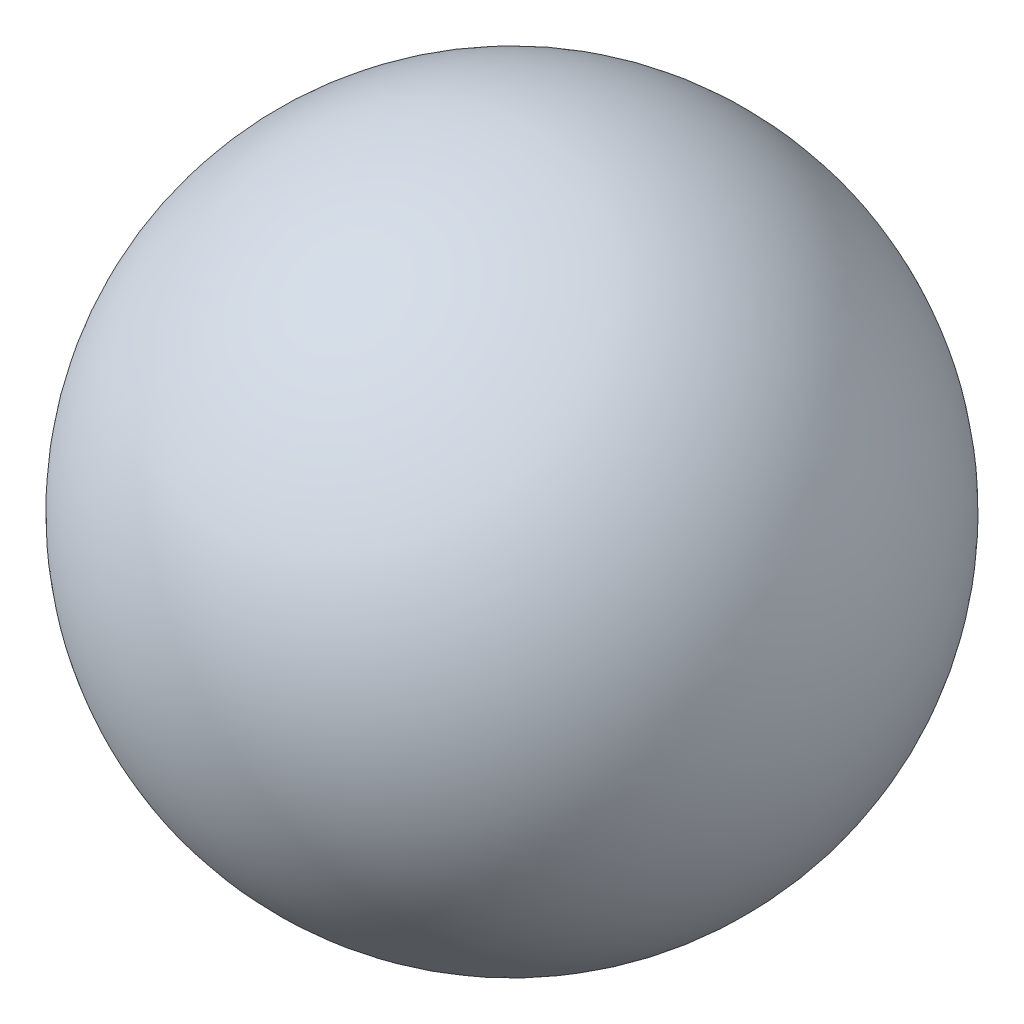
from build123d import *


with BuildPart() as part:
    # 草图1 one side → 旋转2 (revolve)
    with BuildSketch(Plane(origin=(0, 0, 0), x_dir=(1, 0, 0), z_dir=(0, 1, 0))):
        with BuildLine():
            ThreePointArc((0, -4), (2.828427125, -2.828427125), (4, 0))
            ThreePointArc((4, 0), (2.828427125, 2.828427125), (0, 4))
            Line((0, 4), (0, -4))
        make_face()
    revolve(axis=Axis((0, 0, -6.936103092), (0, 0, 1)))


solid = part.part
